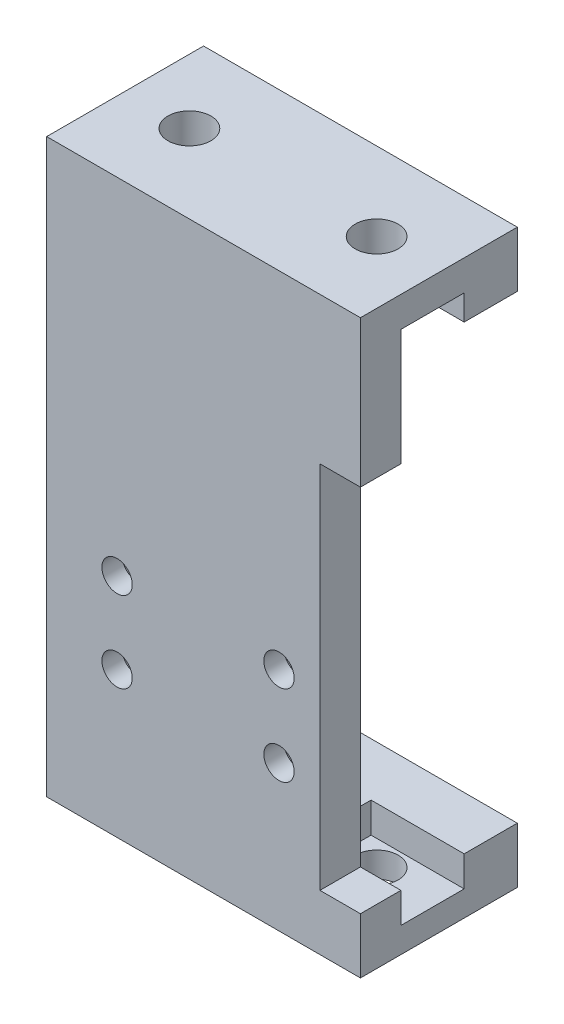
from build123d import *

# Parameters (mm, degrees)
BOSS_EXTRUDE1_DEPTH = 4
SKETCH2_R           = 1.5
BOSS_EXTRUDE2_DEPTH = 2
BOSS_EXTRUDE3_DEPTH = 5.5
SKETCH4_R           = 2.125
BOSS_EXTRUDE4_DEPTH = 3
SKETCH6_W           = 31
SKETCH6_H           = 15.5
SKETCH6_R           = 2.155122413
SKETCH6_R_2         = 2.125
BOSS_EXTRUDE5_DEPTH = 5.5
CUT_EXTRUDE4_DEPTH  = 3


with BuildPart() as part:
    # Sketch1 → Boss-Extrude1 (new body)
    with BuildSketch(Plane.XY):
        Polygon((0, 51), (31, 51), (31, 36.5), (27, 36.5), (27, 0), (0, 0), align=None)
        Polygon((24.165093822, 18.975641236), (21.740222692, 18.975641236), (20.527787127, 16.875641236), (21.740222692, 14.775641236), (24.165093822, 14.775641236), (25.377529388, 16.875641236), align=None, mode=Mode.SUBTRACT)
        Polygon((24.165093822, 10.975641236), (21.740222692, 10.975641236), (20.527787127, 8.875641236), (21.740222692, 6.775641236), (24.165093822, 6.775641236), (25.377529388, 8.875641236), align=None, mode=Mode.SUBTRACT)
        Polygon((8.165093822, 18.975641236), (5.740222692, 18.975641236), (4.527787127, 16.875641236), (5.740222692, 14.775641236), (8.165093822, 14.775641236), (9.377529388, 16.875641236), align=None, mode=Mode.SUBTRACT)
        Polygon((8.165093822, 10.975641236), (5.740222692, 10.975641236), (4.527787127, 8.875641236), (5.740222692, 6.775641236), (8.165093822, 6.775641236), (9.377529388, 8.875641236), align=None, mode=Mode.SUBTRACT)
    extrude(amount=BOSS_EXTRUDE1_DEPTH)

    # Sketch2 → Boss-Extrude2 (add)
    with BuildSketch(Plane.XY.offset(4)):
        Polygon((0, 51), (31, 51), (31, 36.5), (27, 36.5), (27, -2), (0, -2), align=None)
        with Locations((22.952658257, 16.875641236)):
            Circle(SKETCH2_R, mode=Mode.SUBTRACT)
        with Locations((22.952658257, 8.875641236)):
            Circle(SKETCH2_R, mode=Mode.SUBTRACT)
        with Locations((6.952658257, 8.875641236)):
            Circle(SKETCH2_R, mode=Mode.SUBTRACT)
        with Locations((6.952658257, 16.875641236)):
            Circle(SKETCH2_R, mode=Mode.SUBTRACT)
    extrude(amount=-BOSS_EXTRUDE2_DEPTH)

    # Sketch3 → Boss-Extrude3 (add)
    with BuildSketch(Plane(origin=(0, 51, 0), x_dir=(1, 0, 0), z_dir=(0, 1, 0))):
        Polygon((10.9, 0), (20.3, 0), (21.8, 1.5), (21.8, 6.25), (31, 6.25), (31, 11.5), (0, 11.5), (0, 11.25), (0, 6.25), (1.8, 6.25), (9.4, 6.25), (9.4, 1.5), align=None)
    extrude(amount=-BOSS_EXTRUDE3_DEPTH)

    # Sketch4 → Boss-Extrude4 (add)
    with BuildSketch(Plane(origin=(0, 51, 0), x_dir=(1, 0, 0), z_dir=(0, 1, 0))):
        Polygon((31, -4), (0, -4), (0, 11.5), (31, 11.5), (31, 0), align=None)
        with Locations((6.35, 3.75)):
            Circle(SKETCH4_R, mode=Mode.SUBTRACT)
        with Locations((24.85, 3.75)):
            Circle(SKETCH4_R, mode=Mode.SUBTRACT)
    extrude(amount=-BOSS_EXTRUDE4_DEPTH)

    # Sketch6 → Boss-Extrude5 (add)
    with BuildSketch(Plane.XZ):
        with Locations((15.5, -3.75)):
            Rectangle(SKETCH6_W, SKETCH6_H)
        with Locations((6.35, -3.75)):
            Circle(SKETCH6_R, mode=Mode.SUBTRACT)
        with Locations((24.85, -3.75)):
            Circle(SKETCH6_R_2, mode=Mode.SUBTRACT)
    extrude(amount=BOSS_EXTRUDE5_DEPTH)

    # Sketch7 → Cut-Extrude4 (cut)
    with BuildSketch(Plane.XZ):
        Polygon((10.9, 0), (0, 0), (0, -6.25), (9.4, -6.25), (9.4, -1.5), align=None)
        Polygon((20.3, 0), (31, 0), (31, -6.25), (21.8, -6.25), (21.8, -1.5), align=None)
    extrude(amount=CUT_EXTRUDE4_DEPTH, mode=Mode.SUBTRACT)


solid = part.part
